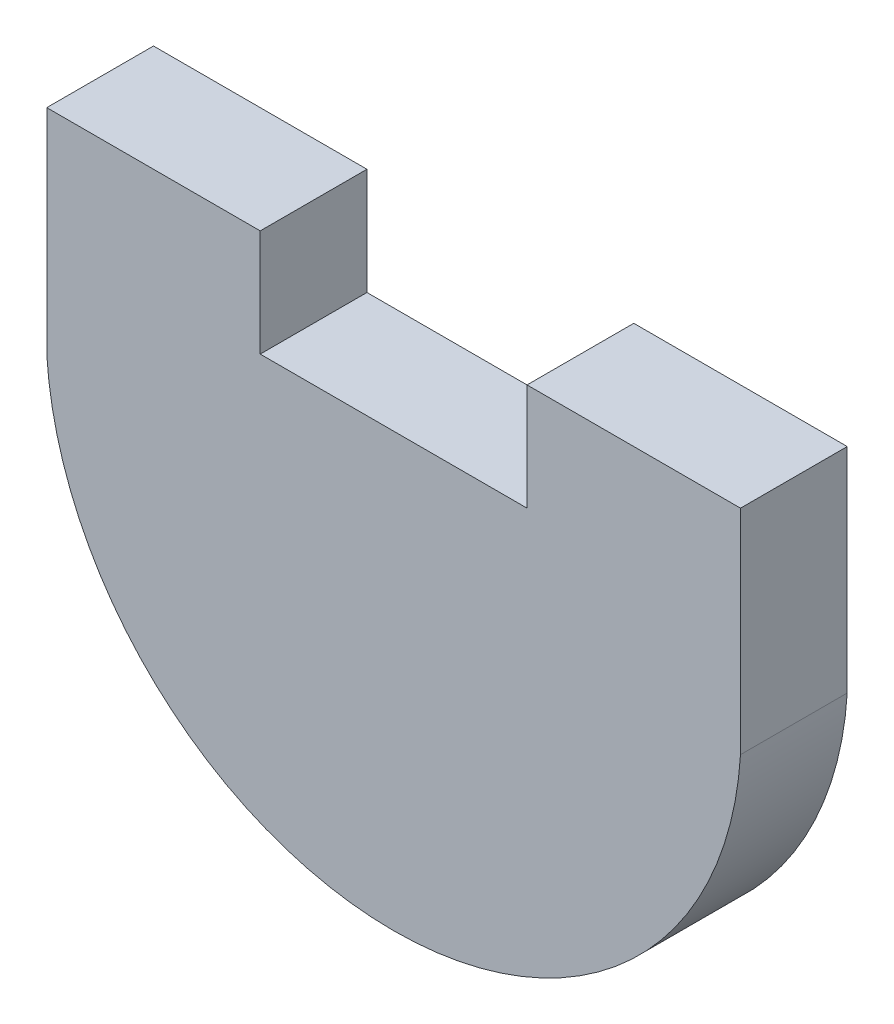
from build123d import *

# Parameters (mm, degrees)
BOSS_EXTRUDE1_DEPTH = 5.08
SKETCH2_W           = 12.7
SKETCH2_H           = 5.08
CUT_EXTRUDE1_DEPTH  = 5.08


with BuildPart() as part:
    # Sketch1 → Boss-Extrude1 (new body)
    with BuildSketch(Plane.XY):
        with BuildLine():
            Line((-16.51, 12.7), (16.51, 12.7))
            Line((16.51, 12.7), (16.51, 2.54))
            ThreePointArc((16.51, 2.54), (0, -12.974722603), (-16.51, 2.54))
            Line((-16.51, 2.54), (-16.51, 12.7))
        make_face()
    extrude(amount=BOSS_EXTRUDE1_DEPTH)

    # Sketch2 → Cut-Extrude1 (cut)
    with BuildSketch(Plane.XY.offset(5.08)):
        with Locations((0, 10.16)):
            Rectangle(SKETCH2_W, SKETCH2_H)
    extrude(amount=-CUT_EXTRUDE1_DEPTH, mode=Mode.SUBTRACT)


solid = part.part
